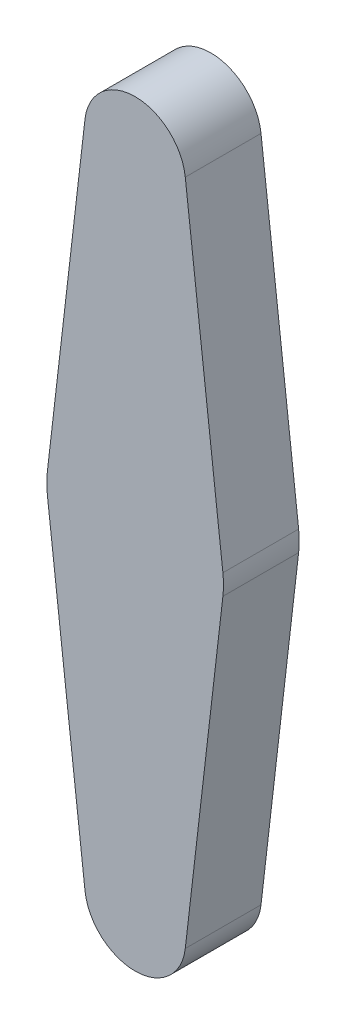
from build123d import *

# Parameters (mm, degrees)
EXTRUDE_1_DEPTH = 3


with BuildPart() as part:
    # 草图1 → 凸台-拉伸1 (new body)
    with BuildSketch(Plane.XY):
        with BuildLine():
            Line((-1.98664178, 13.230769231), (-3.476623115, 0.403846154))
            ThreePointArc((-3.476623115, 0.403846154), (-3.5, 0), (-3.476623115, -0.403846154))
            Line((-3.476623115, -0.403846154), (-1.98664178, -13.230769231))
            ThreePointArc((-1.98664178, -13.230769231), (0, -15), (1.98664178, -13.230769231))
            Line((1.98664178, -13.230769231), (3.476623115, -0.403846154))
            ThreePointArc((3.476623115, -0.403846154), (3.5, 0), (3.476623115, 0.403846154))
            Line((3.476623115, 0.403846154), (1.98664178, 13.230769231))
            ThreePointArc((1.98664178, 13.230769231), (0, 15), (-1.98664178, 13.230769231))
        make_face()
    extrude(amount=EXTRUDE_1_DEPTH)


solid = part.part
